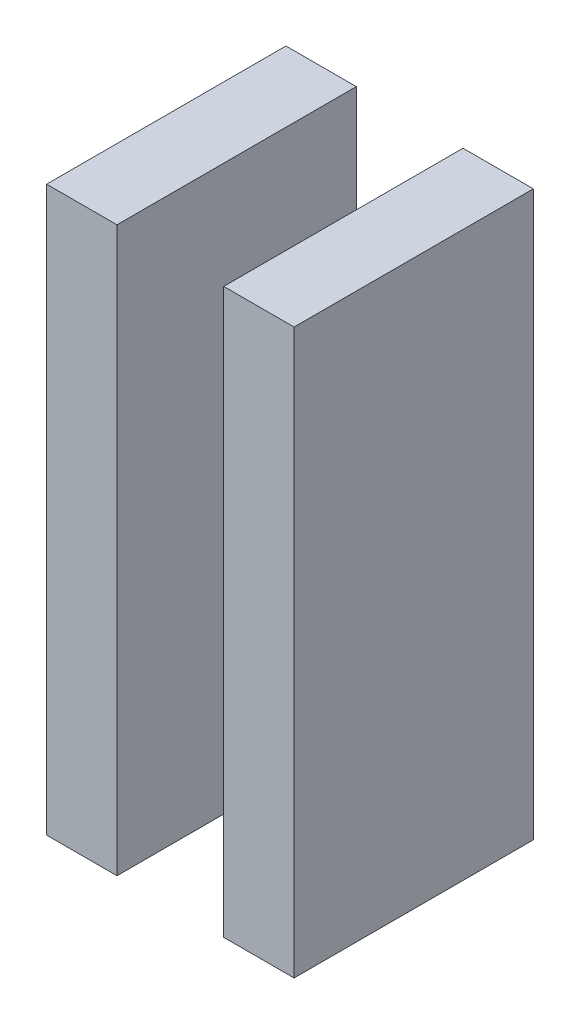
from build123d import *

# Parameters (mm, degrees)
AUFSATZ_LINEAR_START              = 1
SKIZZE1_W                         = 2.94
SKIZZE1_H                         = 23.56
AUFSATZ_LINEAR_AUSTRAGEN1_DEPTH   = 10
AUFSATZ_LINEAR_AUSTRAGEN1_2_DEPTH = 10


with BuildPart() as part:
    # Skizze1 → Aufsatz-Linear austragen1 (new body)
    with BuildSketch(Plane.XY.offset(AUFSATZ_LINEAR_START)):
        with Locations((149.3025, -66.225)):
            Rectangle(SKIZZE1_W, SKIZZE1_H)
    extrude(amount=AUFSATZ_LINEAR_AUSTRAGEN1_DEPTH)


with BuildPart() as body_2:
    # Skizze1 → Aufsatz-Linear austragen1 2 (new body)
    with BuildSketch(Plane.XY.offset(AUFSATZ_LINEAR_START)):
        with Locations((156.7025, -66.225)):
            Rectangle(SKIZZE1_W, SKIZZE1_H)
    extrude(amount=AUFSATZ_LINEAR_AUSTRAGEN1_2_DEPTH)


solid = Compound([part.part, body_2.part])
